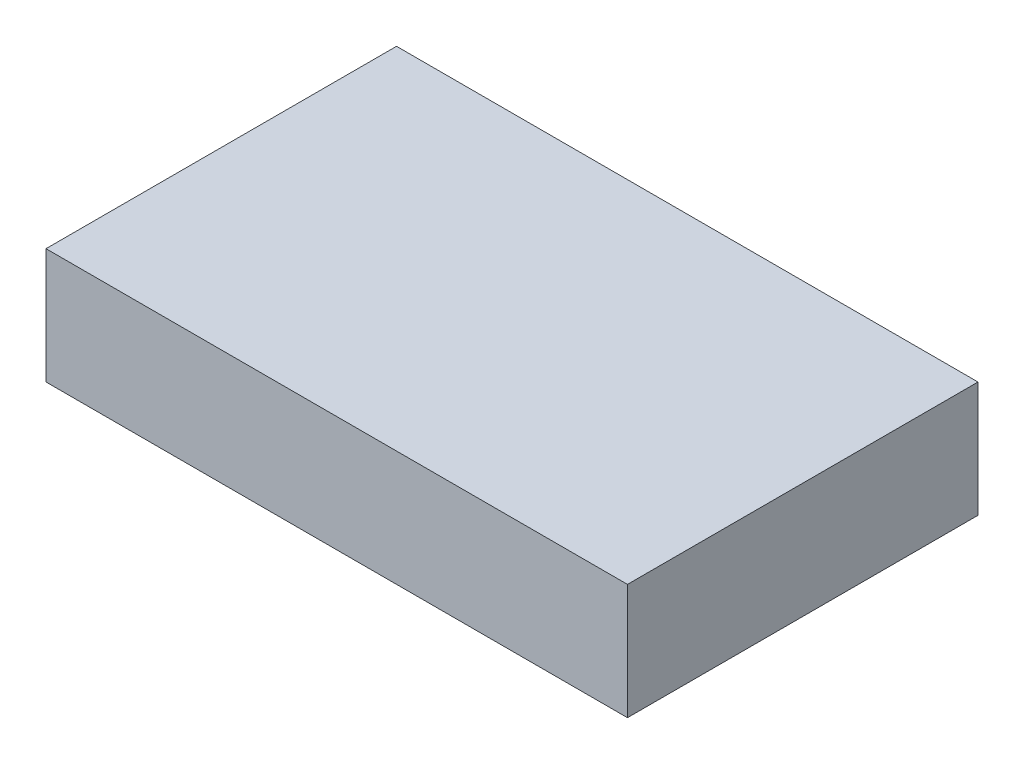
from build123d import *

# Parameters (mm, degrees)
SKETCH1_W           = 141
SKETCH1_H           = 85
BOSS_EXTRUDE1_DEPTH = 28


with BuildPart() as part:
    # Sketch1 → Boss-Extrude1 (new body)
    with BuildSketch(Plane(origin=(0, 0, 0), x_dir=(1, 0, 0), z_dir=(0, 1, 0))):
        Rectangle(SKETCH1_W, SKETCH1_H)
    extrude(amount=BOSS_EXTRUDE1_DEPTH)


solid = part.part
